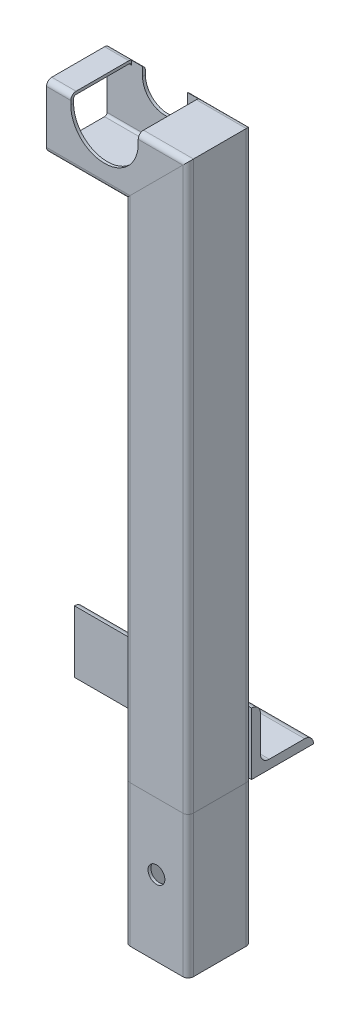
from build123d import *

# Parameters (mm, degrees)
STRUCTURAL_MEMBERMAIN_DEPTH        = 1
STRUCTURAL_MEMBERMAIN_DEPTH_BACK   = 80
STRUCTURAL_MEMBERMAIN_2_DEPTH      = 329.314422766
STRUCTURAL_MEMBERMAIN_3_DEPTH      = 88.414422766
CUT_EXTRUDETOPRAILGUIDE_DEPTH      = 391.78752399
CUT_EXTRUDETOPRAILGUIDE_DEPTH_BACK = 391.78752399
STRUCTURAL_MEMBERANGLE_DEPTH       = 100
SKETCH15_R                         = 4.7625
SKETCH15_R_2                       = 5.044092484
CUT_EXTRUDEMOUNTINGHOLES_DEPTH     = 394.945286691
CUT_EXTRUDEENLARGERAILGUIDE_START  = -16.3
CUT_EXTRUDEENLARGERAILGUIDE_DEPTH  = 34.2
SKETCH17_R                         = 4.7625
CUT_EXTRUDE1_DEPTH                 = 397.745660224


with BuildPart() as part:
    # Sketch11 → Structural MemberMain (new, two sides)
    with BuildSketch(Plane(origin=(205.8375, 0, 0), x_dir=(-1, 0, 0), z_dir=(0, 1, 0))) as structural_membermain_sk:
        with BuildLine():
            Line((-14.9, 17.9), (14.9, 17.9))
            ThreePointArc((14.9, 17.9), (17.021320344, 17.021320344), (17.9, 14.9))
            Line((17.9, 14.9), (17.9, -14.9))
            ThreePointArc((17.9, -14.9), (17.021320344, -17.021320344), (14.9, -17.9))
            Line((14.9, -17.9), (-14.9, -17.9))
            ThreePointArc((-14.9, -17.9), (-17.021320344, -17.021320344), (-17.9, -14.9))
            Line((-17.9, -14.9), (-17.9, 14.9))
            ThreePointArc((-17.9, 14.9), (-17.021320344, 17.021320344), (-14.9, 17.9))
        make_face()
        with BuildLine():
            Line((-14.9, 16.3), (14.9, 16.3))
            ThreePointArc((14.9, 16.3), (15.889949494, 15.889949494), (16.3, 14.9))
            Line((16.3, 14.9), (16.3, -14.9))
            ThreePointArc((16.3, -14.9), (15.889949494, -15.889949494), (14.9, -16.3))
            Line((14.9, -16.3), (-14.9, -16.3))
            ThreePointArc((-14.9, -16.3), (-15.889949494, -15.889949494), (-16.3, -14.9))
            Line((-16.3, -14.9), (-16.3, 14.9))
            ThreePointArc((-16.3, 14.9), (-15.889949494, 15.889949494), (-14.9, 16.3))
        make_face(mode=Mode.SUBTRACT)
    extrude(amount=STRUCTURAL_MEMBERMAIN_DEPTH)
    extrude(structural_membermain_sk.sketch, amount=-STRUCTURAL_MEMBERMAIN_DEPTH_BACK)

    # Structural MemberMain mitre 1
    split(bisect_by=Plane(origin=(205.8375, 0, 0), x_dir=(1, 0, 0), z_dir=(0, -1, 0)), keep=Keep.TOP)

    # Sketch17 → Cut-Extrude1 (cut, through all)
    with BuildSketch(Plane.XY.offset(17.9)):
        with Locations((205.8375, -37.5)):
            Circle(SKETCH17_R)
    extrude(amount=-CUT_EXTRUDE1_DEPTH, mode=Mode.SUBTRACT)


with BuildPart() as body_2:
    # Sketch11 on segment 2 (carried to segment 2) → Structural MemberMain 2 (new body)
    with BuildSketch(Plane(origin=(205.8375, -1, 0), x_dir=(-1, 0, 0), z_dir=(0, 1, 0))):
        with BuildLine():
            Line((-14.9, 17.9), (14.9, 17.9))
            ThreePointArc((14.9, 17.9), (17.021320344, 17.021320344), (17.9, 14.9))
            Line((17.9, 14.9), (17.9, -14.9))
            ThreePointArc((17.9, -14.9), (17.021320344, -17.021320344), (14.9, -17.9))
            Line((14.9, -17.9), (-14.9, -17.9))
            ThreePointArc((-14.9, -17.9), (-17.021320344, -17.021320344), (-17.9, -14.9))
            Line((-17.9, -14.9), (-17.9, 14.9))
            ThreePointArc((-17.9, 14.9), (-17.021320344, 17.021320344), (-14.9, 17.9))
        make_face()
        with BuildLine():
            Line((-14.9, 16.3), (14.9, 16.3))
            ThreePointArc((14.9, 16.3), (15.889949494, 15.889949494), (16.3, 14.9))
            Line((16.3, 14.9), (16.3, -14.9))
            ThreePointArc((16.3, -14.9), (15.889949494, -15.889949494), (14.9, -16.3))
            Line((14.9, -16.3), (-14.9, -16.3))
            ThreePointArc((-14.9, -16.3), (-15.889949494, -15.889949494), (-16.3, -14.9))
            Line((-16.3, -14.9), (-16.3, 14.9))
            ThreePointArc((-16.3, 14.9), (-15.889949494, 15.889949494), (-14.9, 16.3))
        make_face(mode=Mode.SUBTRACT)
    extrude(amount=STRUCTURAL_MEMBERMAIN_2_DEPTH)

    # Structural MemberMain 2 mitre 1
    split(bisect_by=Plane(origin=(205.8375, 0, 0), x_dir=(-1, 0, 0), z_dir=(0, 1, 0)), keep=Keep.TOP)

    # Structural MemberMain 2 mitre 2
    split(bisect_by=Plane(origin=(205.8375, 302, 0), x_dir=(0.707106781, 0.707106781, 0), z_dir=(0.707106781, -0.707106781, 0)), keep=Keep.TOP)


with BuildPart() as body_3:
    # Sketch11 on segment 3 (carried to segment 3) → Structural MemberMain 3 (new body)
    with BuildSketch(Plane(origin=(232.151922766, 302, 0), x_dir=(0, -1, 0), z_dir=(-1, 0, 0))):
        with BuildLine():
            Line((-14.9, 17.9), (14.9, 17.9))
            ThreePointArc((14.9, 17.9), (17.021320344, 17.021320344), (17.9, 14.9))
            Line((17.9, 14.9), (17.9, -14.9))
            ThreePointArc((17.9, -14.9), (17.021320344, -17.021320344), (14.9, -17.9))
            Line((14.9, -17.9), (-14.9, -17.9))
            ThreePointArc((-14.9, -17.9), (-17.021320344, -17.021320344), (-17.9, -14.9))
            Line((-17.9, -14.9), (-17.9, 14.9))
            ThreePointArc((-17.9, 14.9), (-17.021320344, 17.021320344), (-14.9, 17.9))
        make_face()
        with BuildLine():
            Line((-14.9, 16.3), (14.9, 16.3))
            ThreePointArc((14.9, 16.3), (15.889949494, 15.889949494), (16.3, 14.9))
            Line((16.3, 14.9), (16.3, -14.9))
            ThreePointArc((16.3, -14.9), (15.889949494, -15.889949494), (14.9, -16.3))
            Line((14.9, -16.3), (-14.9, -16.3))
            ThreePointArc((-14.9, -16.3), (-15.889949494, -15.889949494), (-16.3, -14.9))
            Line((-16.3, -14.9), (-16.3, 14.9))
            ThreePointArc((-16.3, 14.9), (-15.889949494, 15.889949494), (-14.9, 16.3))
        make_face(mode=Mode.SUBTRACT)
    extrude(amount=STRUCTURAL_MEMBERMAIN_3_DEPTH)

    # Structural MemberMain 3 mitre 1
    split(bisect_by=Plane(origin=(205.8375, 302, 0), x_dir=(-0.707106781, -0.707106781, 0), z_dir=(-0.707106781, 0.707106781, 0)), keep=Keep.TOP)

    # Sketch12 → Cut-ExtrudeTopRailGuide (cut, two sides)
    with BuildSketch(Plane.XY) as cut_extrudetoprailguide_sk:
        with BuildLine():
            Line((163.8, 314.7), (163.8, 325.1))
            ThreePointArc((163.8, 325.1), (176.5, 337.8), (189.2, 325.1))
            Line((189.2, 325.1), (189.2, 314.7))
            ThreePointArc((189.2, 314.7), (176.5, 302), (163.8, 314.7))
        make_face()
    extrude(amount=CUT_EXTRUDETOPRAILGUIDE_DEPTH, mode=Mode.SUBTRACT)
    extrude(cut_extrudetoprailguide_sk.sketch, amount=-CUT_EXTRUDETOPRAILGUIDE_DEPTH_BACK, mode=Mode.SUBTRACT)

    # Sketch16 → Cut-ExtrudeEnlargeRailGuide (cut)
    with BuildSketch(Plane.XY.offset(CUT_EXTRUDEENLARGERAILGUIDE_START)):
        with BuildLine():
            Line((195.55, 314.7), (195.55, 325.1))
            ThreePointArc((195.55, 325.1), (176.5, 344.15), (157.45, 325.1))
            Line((157.45, 325.1), (157.45, 314.7))
            ThreePointArc((157.45, 314.7), (176.5, 295.65), (195.55, 314.7))
        make_face()
    extrude(amount=CUT_EXTRUDEENLARGERAILGUIDE_DEPTH, mode=Mode.SUBTRACT)


with BuildPart() as body_4:
    # Sketch14 → Structural MemberAngle (new body)
    with BuildSketch(Plane(origin=(123.7375, 0, -17.9), x_dir=(0, 0, -1), z_dir=(1, 0, 0))):
        with BuildLine():
            Line((0, 0), (0, 35))
            ThreePointArc((0, 35), (3.535533906, 33.535533906), (5, 30))
            Line((5, 30), (5, 10))
            ThreePointArc((5, 10), (6.464466094, 6.464466094), (10, 5))
            Line((10, 5), (30, 5))
            ThreePointArc((30, 5), (33.535533906, 3.535533906), (35, 0))
            Line((35, 0), (0, 0))
        make_face()
    extrude(amount=STRUCTURAL_MEMBERANGLE_DEPTH)

    # Sketch15 → Cut-ExtrudeMountingHoles (cut, through all)
    with BuildSketch(Plane(origin=(0, 0, 0), x_dir=(1, 0, 0), z_dir=(0, 1, 0))):
        with Locations(Location((157.7, 37.9, 0), (0, 0, 90))):
            Circle(SKETCH15_R)
        with Locations(Location((192.7, 37.9, 0), (0, 0, 90))):
            Circle(SKETCH15_R_2)
    extrude(amount=CUT_EXTRUDEMOUNTINGHOLES_DEPTH, mode=Mode.SUBTRACT)


solid = Compound([part.part, body_2.part, body_3.part, body_4.part])
